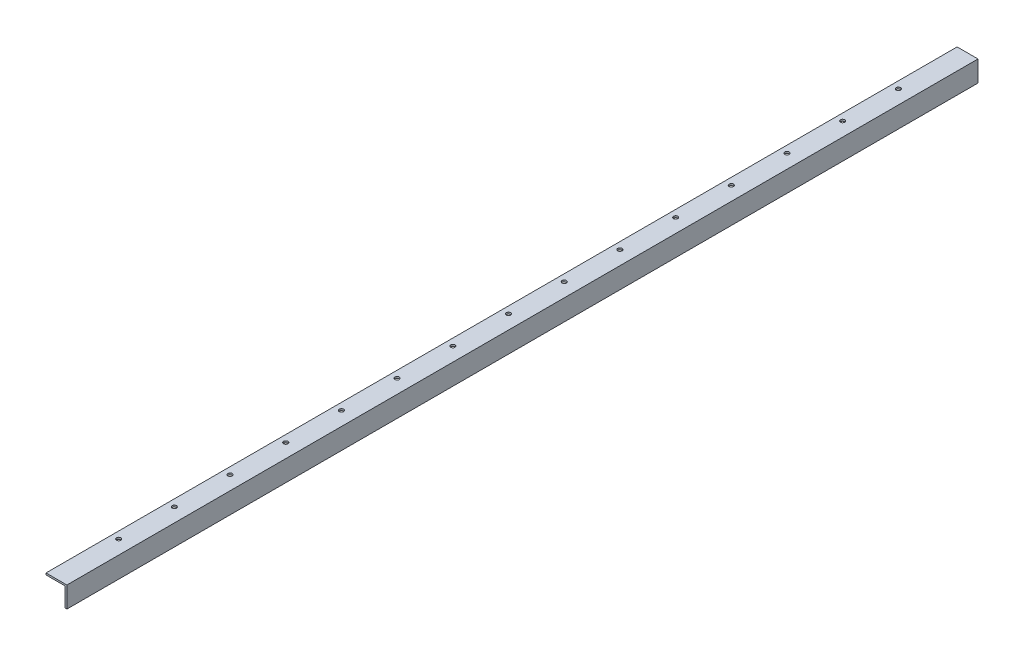
from build123d import *

# Parameters (mm, degrees)
BOSS_EXTRUDE1_DEPTH = 1662.1125
SKETCH4_R           = 3.96875
CUT_EXTRUDE3_DEPTH  = 44.45
LPATTERN1_COUNT     = 15
LPATTERN1_PITCH     = 101.6


with BuildPart() as part:
    # Sketch1 → Boss-Extrude1 (new body)
    with BuildSketch(Plane.XY):
        Polygon((0, 0), (-38.1, 0), (-38.1, -3.175), (-3.175, -3.175), (-3.175, -38.1), (0, -38.1), align=None)
    extrude(amount=BOSS_EXTRUDE1_DEPTH)

    # Sketch4 → Cut-Extrude3 (cut)
    with BuildSketch(Plane(origin=(10.670100368, 3.175, 817.757022881), x_dir=(1, 0, 0), z_dir=(0, 1, 0))):
        with Locations((-36.070100368, 697.900772881)):
            Circle(SKETCH4_R)
    cut_extrude3 = extrude(amount=-CUT_EXTRUDE3_DEPTH, mode=Mode.SUBTRACT)

    # LPattern1: Cut-Extrude3 ×15
    with Locations(*[(0, 0, i * LPATTERN1_PITCH) for i in range(1, LPATTERN1_COUNT)]):
        add(cut_extrude3, mode=Mode.SUBTRACT)


solid = part.part
